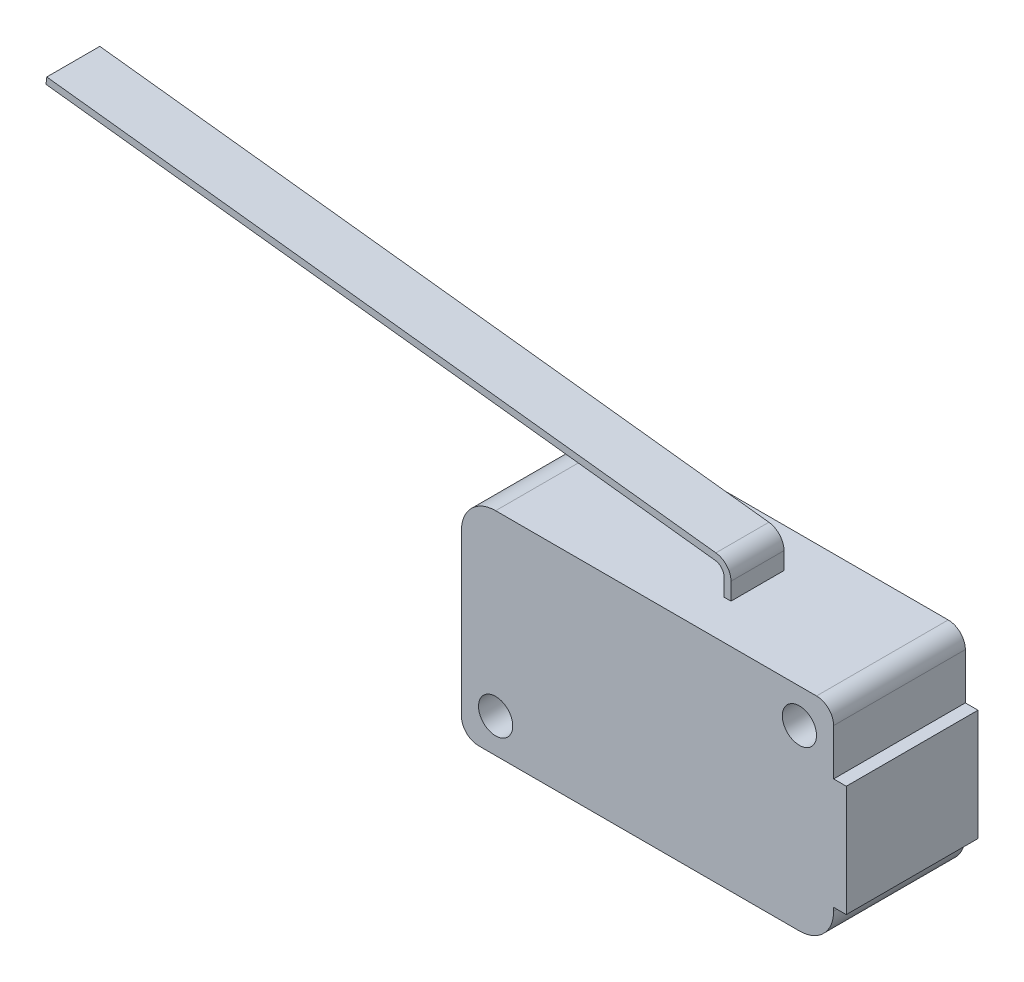
from build123d import *

# Parameters (mm, degrees)
EXTRUDE_THIN1_DEPTH = 1.9685
SKETCH2_R           = 1.27
BOSS_EXTRUDE1_DEPTH = 4.8895


with BuildPart() as part:
    # Sketch1 → Extrude-Thin1 (new body)
    with BuildSketch(Plane.XY):
        with BuildLine():
            Line((-50.8, 8.3058), (-1.123661277, 2.543344708))
            ThreePointArc((-1.123661277, 2.543344708), (-0.321646116, 2.12650803), (0, 1.281803992))
            Line((0, 1.281803992), (0, 0))
            Line((0, 0), (-0.508, 0))
            Line((-0.508, 0), (-0.508, 1.281803992))
            ThreePointArc((-0.508, 1.281803992), (-0.70098767, 1.788626415), (-1.182196766, 2.038728422))
            Line((-1.182196766, 2.038728422), (-50.858535489, 7.801183714))
            Line((-50.858535489, 7.801183714), (-50.8, 8.3058))
        make_face()
    extrude_thin1 = extrude(amount=-EXTRUDE_THIN1_DEPTH)

    # Sketch2 → Boss-Extrude1 (add)
    with BuildSketch(Plane.XY):
        with BuildLine():
            Line((-14.5542, 0), (9.271, 0))
            ThreePointArc((9.271, 0), (10.169025612, -0.371974388), (10.541, -1.27))
            Line((10.541, -1.27), (10.541, -4.699))
            Line((10.541, -4.699), (11.4808, -4.699))
            Line((11.4808, -4.699), (11.4808, -12.954))
            Line((11.4808, -12.954), (10.541, -12.954))
            Line((10.541, -12.954), (10.541, -13.208))
            ThreePointArc((10.541, -13.208), (9.797051224, -15.004051224), (8.001, -15.748))
            Line((8.001, -15.748), (-15.8242, -15.748))
            ThreePointArc((-15.8242, -15.748), (-16.722225612, -15.376025612), (-17.0942, -14.478))
            Line((-17.0942, -14.478), (-17.0942, -2.54))
            ThreePointArc((-17.0942, -2.54), (-16.350251224, -0.743948776), (-14.5542, 0))
        make_face()
        with Locations((8.001, -2.54)):
            Circle(SKETCH2_R, mode=Mode.SUBTRACT)
        with Locations((-14.5542, -13.208)):
            Circle(SKETCH2_R, mode=Mode.SUBTRACT)
    boss_extrude1 = extrude(amount=-BOSS_EXTRUDE1_DEPTH)

    # Mirror1: Extrude-Thin1, Boss-Extrude1 across Front Plane
    add(extrude_thin1.mirror(Plane.XY))
    add(boss_extrude1.mirror(Plane.XY))


solid = part.part
